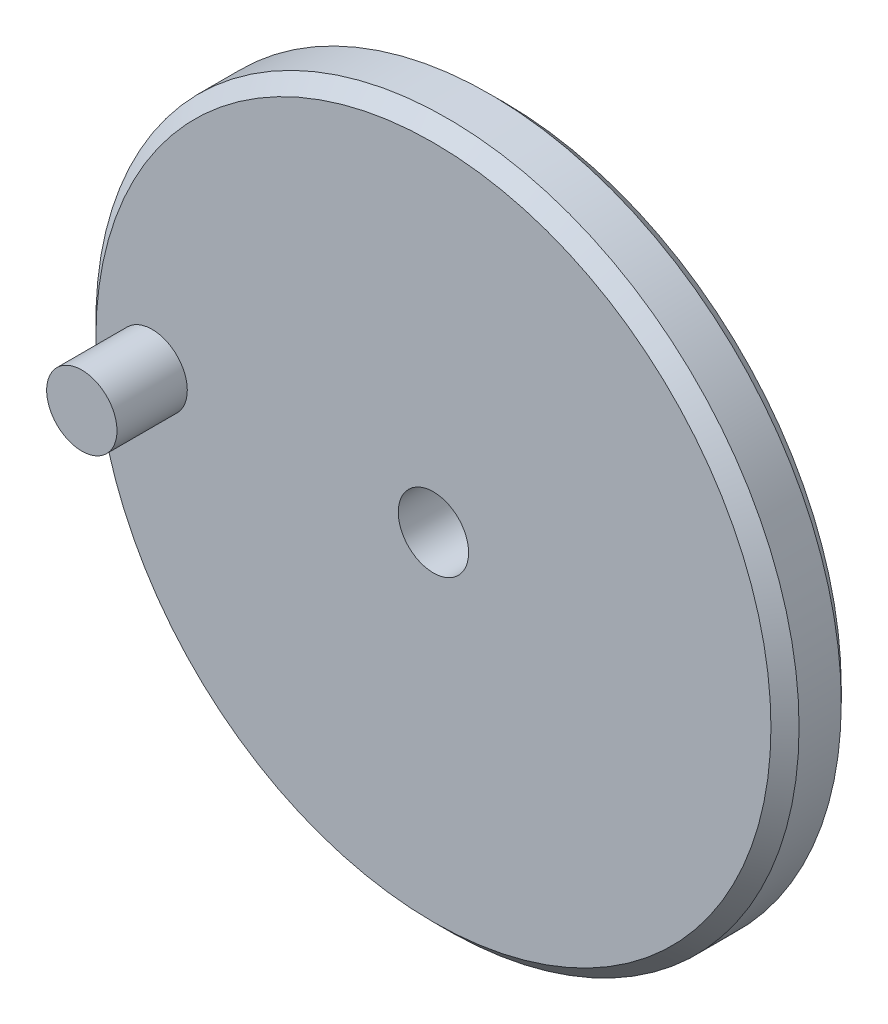
from build123d import *

# Parameters (mm, degrees)
SKETCH1_R           = 25
SKETCH1_R_2         = 2.5
BOSS_EXTRUDE1_DEPTH = 5
SKETCH2_R           = 2.5
BOSS_EXTRUDE2_DEPTH = 5
CHAMFER1_SIZE       = 1


with BuildPart() as part:
    # Sketch1 → Boss-Extrude1 (new body)
    with BuildSketch(Plane.XY):
        Circle(SKETCH1_R)
        Circle(SKETCH1_R_2, mode=Mode.SUBTRACT)
    extrude(amount=BOSS_EXTRUDE1_DEPTH)

    # Sketch2 → Boss-Extrude2 (add)
    with BuildSketch(Plane.XY.offset(5)):
        with Locations((-20, 0)):
            Circle(SKETCH2_R)
    extrude(amount=BOSS_EXTRUDE2_DEPTH)

    # Chamfer1
    chamfer1_edges = [part.edges().sort_by_distance(p)[0] for p in [
        (-25, 0, 0),
        (-25, 0, 5),
    ]]
    chamfer(chamfer1_edges, length=CHAMFER1_SIZE)


solid = part.part
